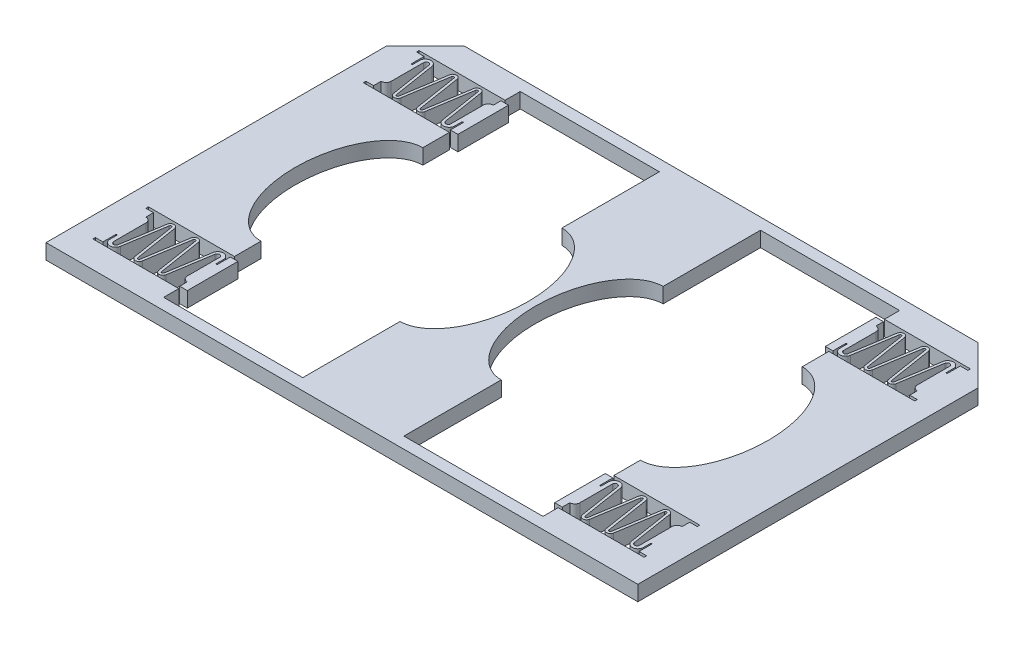
from build123d import *

# Parameters (mm, degrees)
SKETCH1_W           = 27.5
SKETCH1_H           = 70.5
BOSS_EXTRUDE1_DEPTH = 3
SKETCH3_RX          = 16
SKETCH3_RY          = 9.25
SKETCH3_W           = 17
SKETCH3_H           = 11
CUT_EXTRUDE3_DEPTH  = 4
BOSS_EXTRUDE3_DEPTH = 3


with BuildPart() as part:
    # Sketch1 → Boss-Extrude1 (new body)
    with BuildSketch(Plane(origin=(0, 0, 0), x_dir=(1, 0, 0), z_dir=(0, 1, 0))):
        Polygon((0, 67.25), (0, 0), (117, 0), (117, 67.25), (109.25, 75), (7.75, 75), align=None)
        with Locations((34.75, 37.5)):
            Rectangle(SKETCH1_W, SKETCH1_H, mode=Mode.SUBTRACT)
        with Locations((82.25, 37.5)):
            Rectangle(SKETCH1_W, SKETCH1_H, mode=Mode.SUBTRACT)
    extrude(amount=BOSS_EXTRUDE1_DEPTH)

    # Sketch3 → Cut-Extrude3 (cut, through all)
    with BuildSketch(Plane(origin=(0, 3, 0), x_dir=(1, 0, 0), z_dir=(0, 1, 0))):
        with Locations(Location((21, 37.5), (0, 0, -90))):
            Ellipse(SKETCH3_RX, SKETCH3_RY)
        with Locations(Location((48.5, 37.5), (0, 0, 90))):
            Ellipse(SKETCH3_RX, SKETCH3_RY)
        with Locations(Location((68.5, 37.5), (0, 0, 90))):
            Ellipse(SKETCH3_RX, SKETCH3_RY)
        with Locations(Location((96, 37.5), (0, 0, 90))):
            Ellipse(SKETCH3_RX, SKETCH3_RY)
        with Locations((104.5, 64.25)):
            Rectangle(SKETCH3_W, SKETCH3_H)
        with Locations((12.5, 64.25)):
            Rectangle(SKETCH3_W, SKETCH3_H)
        with Locations((104.5, 10.75)):
            Rectangle(SKETCH3_W, SKETCH3_H)
        with Locations((12.5, 10.75)):
            Rectangle(SKETCH3_W, SKETCH3_H)
    extrude(amount=-CUT_EXTRUDE3_DEPTH, mode=Mode.SUBTRACT)

    # Sketch5 → Boss-Extrude3 (add)
    with BuildSketch(Plane(origin=(0, 3, 0), x_dir=(1, 0, 0), z_dir=(0, 1, 0))):
        with BuildLine():
            ThreePointArc((5.5, 60.75), (6.207106781, 61.042893219), (6.5, 61.75))
            Line((6.5, 61.75), (6.5, 68.143901182))
            ThreePointArc((6.5, 68.143901182), (6.960770452, 68.642359849), (7.49384417, 68.222118414))
            Line((7.49384417, 68.222118414), (8.814682383, 59.882674151))
            ThreePointArc((8.814682383, 59.882674151), (9.555448638, 59.25), (10.296214893, 59.882674151))
            Line((10.296214893, 59.882674151), (11.667259421, 68.539108616))
            ThreePointArc((11.667259421, 68.539108616), (11.914181507, 68.75), (12.161103592, 68.539108616))
            Line((12.161103592, 68.539108616), (13.53214812, 59.882674151))
            ThreePointArc((13.53214812, 59.882674151), (14.272914375, 59.25), (15.013680631, 59.882674151))
            Line((15.013680631, 59.882674151), (16.384725158, 68.539108616))
            ThreePointArc((16.384725158, 68.539108616), (16.631647244, 68.75), (16.878569329, 68.539108616))
            Line((16.878569329, 68.539108616), (18.199407541, 60.199664353))
            ThreePointArc((18.199407541, 60.199664353), (19.399648866, 59.253470386), (20.437095882, 60.375774245))
            Line((20.437095882, 60.375774245), (20.437095882, 61.75))
            ThreePointArc((20.437095882, 61.75), (20.562095882, 61.875), (20.687095882, 61.75))
            Line((20.687095882, 61.75), (20.687095882, 59.25))
            Line((20.687095882, 59.25), (22.187095882, 59.25))
            Line((22.187095882, 59.25), (22.187095882, 69.25))
            Line((22.187095882, 69.25), (20.687095882, 69.25))
            Line((20.687095882, 69.25), (20.687095882, 67.75))
            ThreePointArc((20.687095882, 67.75), (19.9799891, 67.457106781), (19.687095882, 66.75))
            Line((19.687095882, 66.75), (19.687095882, 60.356098818))
            ThreePointArc((19.687095882, 60.356098818), (19.226325429, 59.857640151), (18.693251711, 60.277881586))
            Line((18.693251711, 60.277881586), (17.372413499, 68.617325849))
            ThreePointArc((17.372413499, 68.617325849), (16.631647244, 69.25), (15.890880988, 68.617325849))
            Line((15.890880988, 68.617325849), (14.51983646, 59.960891384))
            ThreePointArc((14.51983646, 59.960891384), (14.272914375, 59.75), (14.02599229, 59.960891384))
            Line((14.02599229, 59.960891384), (12.654947762, 68.617325849))
            ThreePointArc((12.654947762, 68.617325849), (11.914181507, 69.25), (11.173415251, 68.617325849))
            Line((11.173415251, 68.617325849), (9.802370723, 59.960891384))
            ThreePointArc((9.802370723, 59.960891384), (9.555448638, 59.75), (9.308526553, 59.960891384))
            Line((9.308526553, 59.960891384), (7.987688341, 68.300335647))
            ThreePointArc((7.987688341, 68.300335647), (6.787447016, 69.246529614), (5.75, 68.124225755))
            Line((5.75, 68.124225755), (5.75, 66.75))
            ThreePointArc((5.75, 66.75), (5.625, 66.625), (5.5, 66.75))
            Line((5.5, 66.75), (5.5, 69.25))
            Line((5.5, 69.25), (4, 69.25))
            Line((4, 69.25), (4, 59.25))
            Line((4, 59.25), (5.5, 59.25))
            Line((5.5, 59.25), (5.5, 60.75))
        make_face()
        with BuildLine():
            Line((96.312904118, 59.25), (96.312904118, 61.75))
            ThreePointArc((96.312904118, 61.75), (96.437904118, 61.875), (96.562904118, 61.75))
            Line((96.562904118, 61.75), (96.562904118, 60.375774245))
            ThreePointArc((96.562904118, 60.375774245), (97.600351134, 59.253470386), (98.800592459, 60.199664353))
            Line((98.800592459, 60.199664353), (100.121430671, 68.539108616))
            ThreePointArc((100.121430671, 68.539108616), (100.368352756, 68.75), (100.615274842, 68.539108616))
            Line((100.615274842, 68.539108616), (101.986319369, 59.882674151))
            ThreePointArc((101.986319369, 59.882674151), (102.727085625, 59.25), (103.46785188, 59.882674151))
            Line((103.46785188, 59.882674151), (104.838896408, 68.539108616))
            ThreePointArc((104.838896408, 68.539108616), (105.085818493, 68.75), (105.332740579, 68.539108616))
            Line((105.332740579, 68.539108616), (106.703785107, 59.882674151))
            ThreePointArc((106.703785107, 59.882674151), (107.444551362, 59.25), (108.185317617, 59.882674151))
            Line((108.185317617, 59.882674151), (109.50615583, 68.222118414))
            ThreePointArc((109.50615583, 68.222118414), (110.039229548, 68.642359849), (110.5, 68.143901182))
            Line((110.5, 68.143901182), (110.5, 61.75))
            ThreePointArc((110.5, 61.75), (110.792893219, 61.042893219), (111.5, 60.75))
            Line((111.5, 60.75), (111.5, 59.25))
            Line((111.5, 59.25), (113, 59.25))
            Line((113, 59.25), (113, 69.25))
            Line((113, 69.25), (111.5, 69.25))
            Line((111.5, 69.25), (111.5, 66.75))
            ThreePointArc((111.5, 66.75), (111.375, 66.625), (111.25, 66.75))
            Line((111.25, 66.75), (111.25, 68.124225755))
            ThreePointArc((111.25, 68.124225755), (110.212552984, 69.246529614), (109.012311659, 68.300335647))
            Line((109.012311659, 68.300335647), (107.691473447, 59.960891384))
            ThreePointArc((107.691473447, 59.960891384), (107.444551362, 59.75), (107.197629277, 59.960891384))
            Line((107.197629277, 59.960891384), (105.826584749, 68.617325849))
            ThreePointArc((105.826584749, 68.617325849), (105.085818493, 69.25), (104.345052238, 68.617325849))
            Line((104.345052238, 68.617325849), (102.97400771, 59.960891384))
            ThreePointArc((102.97400771, 59.960891384), (102.727085625, 59.75), (102.48016354, 59.960891384))
            Line((102.48016354, 59.960891384), (101.109119012, 68.617325849))
            ThreePointArc((101.109119012, 68.617325849), (100.368352756, 69.25), (99.627586501, 68.617325849))
            Line((99.627586501, 68.617325849), (98.306748289, 60.277881586))
            ThreePointArc((98.306748289, 60.277881586), (97.773674571, 59.857640151), (97.312904118, 60.356098818))
            Line((97.312904118, 60.356098818), (97.312904118, 66.75))
            ThreePointArc((97.312904118, 66.75), (97.0200109, 67.457106781), (96.312904118, 67.75))
            Line((96.312904118, 67.75), (96.312904118, 69.25))
            Line((96.312904118, 69.25), (94.812904118, 69.25))
            Line((94.812904118, 69.25), (94.812904118, 59.25))
            Line((94.812904118, 59.25), (96.312904118, 59.25))
        make_face()
        with BuildLine():
            Line((20.687095882, 15.75), (20.687095882, 13.25))
            ThreePointArc((20.687095882, 13.25), (20.562095882, 13.125), (20.437095882, 13.25))
            Line((20.437095882, 13.25), (20.437095882, 14.624225755))
            ThreePointArc((20.437095882, 14.624225755), (19.399648866, 15.746529614), (18.199407541, 14.800335647))
            Line((18.199407541, 14.800335647), (16.878569329, 6.460891384))
            ThreePointArc((16.878569329, 6.460891384), (16.631647244, 6.25), (16.384725158, 6.460891384))
            Line((16.384725158, 6.460891384), (15.013680631, 15.117325849))
            ThreePointArc((15.013680631, 15.117325849), (14.272914375, 15.75), (13.53214812, 15.117325849))
            Line((13.53214812, 15.117325849), (12.161103592, 6.460891384))
            ThreePointArc((12.161103592, 6.460891384), (11.914181507, 6.25), (11.667259421, 6.460891384))
            Line((11.667259421, 6.460891384), (10.296214893, 15.117325849))
            ThreePointArc((10.296214893, 15.117325849), (9.555448638, 15.75), (8.814682383, 15.117325849))
            Line((8.814682383, 15.117325849), (7.49384417, 6.777881586))
            ThreePointArc((7.49384417, 6.777881586), (6.960770452, 6.357640151), (6.5, 6.856098818))
            Line((6.5, 6.856098818), (6.5, 13.25))
            ThreePointArc((6.5, 13.25), (6.207106781, 13.957106781), (5.5, 14.25))
            Line((5.5, 14.25), (5.5, 15.75))
            Line((5.5, 15.75), (4, 15.75))
            Line((4, 15.75), (4, 5.75))
            Line((4, 5.75), (5.5, 5.75))
            Line((5.5, 5.75), (5.5, 8.25))
            ThreePointArc((5.5, 8.25), (5.625, 8.375), (5.75, 8.25))
            Line((5.75, 8.25), (5.75, 6.875774245))
            ThreePointArc((5.75, 6.875774245), (6.787447016, 5.753470386), (7.987688341, 6.699664353))
            Line((7.987688341, 6.699664353), (9.308526553, 15.039108616))
            ThreePointArc((9.308526553, 15.039108616), (9.555448638, 15.25), (9.802370723, 15.039108616))
            Line((9.802370723, 15.039108616), (11.173415251, 6.382674151))
            ThreePointArc((11.173415251, 6.382674151), (11.914181507, 5.75), (12.654947762, 6.382674151))
            Line((12.654947762, 6.382674151), (14.02599229, 15.039108616))
            ThreePointArc((14.02599229, 15.039108616), (14.272914375, 15.25), (14.51983646, 15.039108616))
            Line((14.51983646, 15.039108616), (15.890880988, 6.382674151))
            ThreePointArc((15.890880988, 6.382674151), (16.631647244, 5.75), (17.372413499, 6.382674151))
            Line((17.372413499, 6.382674151), (18.693251711, 14.722118414))
            ThreePointArc((18.693251711, 14.722118414), (19.226325429, 15.142359849), (19.687095882, 14.643901182))
            Line((19.687095882, 14.643901182), (19.687095882, 8.25))
            ThreePointArc((19.687095882, 8.25), (19.9799891, 7.542893219), (20.687095882, 7.25))
            Line((20.687095882, 7.25), (20.687095882, 5.75))
            Line((20.687095882, 5.75), (22.187095882, 5.75))
            Line((22.187095882, 5.75), (22.187095882, 15.75))
            Line((22.187095882, 15.75), (20.687095882, 15.75))
        make_face()
        with BuildLine():
            ThreePointArc((111.5, 14.25), (110.792893219, 13.957106781), (110.5, 13.25))
            Line((110.5, 13.25), (110.5, 6.856098818))
            ThreePointArc((110.5, 6.856098818), (110.039229548, 6.357640151), (109.50615583, 6.777881586))
            Line((109.50615583, 6.777881586), (108.185317617, 15.117325849))
            ThreePointArc((108.185317617, 15.117325849), (107.444551362, 15.75), (106.703785107, 15.117325849))
            Line((106.703785107, 15.117325849), (105.332740579, 6.460891384))
            ThreePointArc((105.332740579, 6.460891384), (105.085818493, 6.25), (104.838896408, 6.460891384))
            Line((104.838896408, 6.460891384), (103.46785188, 15.117325849))
            ThreePointArc((103.46785188, 15.117325849), (102.727085625, 15.75), (101.986319369, 15.117325849))
            Line((101.986319369, 15.117325849), (100.615274842, 6.460891384))
            ThreePointArc((100.615274842, 6.460891384), (100.368352756, 6.25), (100.121430671, 6.460891384))
            Line((100.121430671, 6.460891384), (98.800592459, 14.800335647))
            ThreePointArc((98.800592459, 14.800335647), (97.600351134, 15.746529614), (96.562904118, 14.624225755))
            Line((96.562904118, 14.624225755), (96.562904118, 13.25))
            ThreePointArc((96.562904118, 13.25), (96.437904118, 13.125), (96.312904118, 13.25))
            Line((96.312904118, 13.25), (96.312904118, 15.75))
            Line((96.312904118, 15.75), (94.812904118, 15.75))
            Line((94.812904118, 15.75), (94.812904118, 5.75))
            Line((94.812904118, 5.75), (96.312904118, 5.75))
            Line((96.312904118, 5.75), (96.312904118, 7.25))
            ThreePointArc((96.312904118, 7.25), (97.0200109, 7.542893219), (97.312904118, 8.25))
            Line((97.312904118, 8.25), (97.312904118, 14.643901182))
            ThreePointArc((97.312904118, 14.643901182), (97.773674571, 15.142359849), (98.306748289, 14.722118414))
            Line((98.306748289, 14.722118414), (99.627586501, 6.382674151))
            ThreePointArc((99.627586501, 6.382674151), (100.368352756, 5.75), (101.109119012, 6.382674151))
            Line((101.109119012, 6.382674151), (102.48016354, 15.039108616))
            ThreePointArc((102.48016354, 15.039108616), (102.727085625, 15.25), (102.97400771, 15.039108616))
            Line((102.97400771, 15.039108616), (104.345052238, 6.382674151))
            ThreePointArc((104.345052238, 6.382674151), (105.085818493, 5.75), (105.826584749, 6.382674151))
            Line((105.826584749, 6.382674151), (107.197629277, 15.039108616))
            ThreePointArc((107.197629277, 15.039108616), (107.444551362, 15.25), (107.691473447, 15.039108616))
            Line((107.691473447, 15.039108616), (109.012311659, 6.699664353))
            ThreePointArc((109.012311659, 6.699664353), (110.212552984, 5.753470386), (111.25, 6.875774245))
            Line((111.25, 6.875774245), (111.25, 8.25))
            ThreePointArc((111.25, 8.25), (111.375, 8.375), (111.5, 8.25))
            Line((111.5, 8.25), (111.5, 5.75))
            Line((111.5, 5.75), (113, 5.75))
            Line((113, 5.75), (113, 15.75))
            Line((113, 15.75), (111.5, 15.75))
            Line((111.5, 15.75), (111.5, 14.25))
        make_face()
    extrude(amount=-BOSS_EXTRUDE3_DEPTH)


solid = part.part
